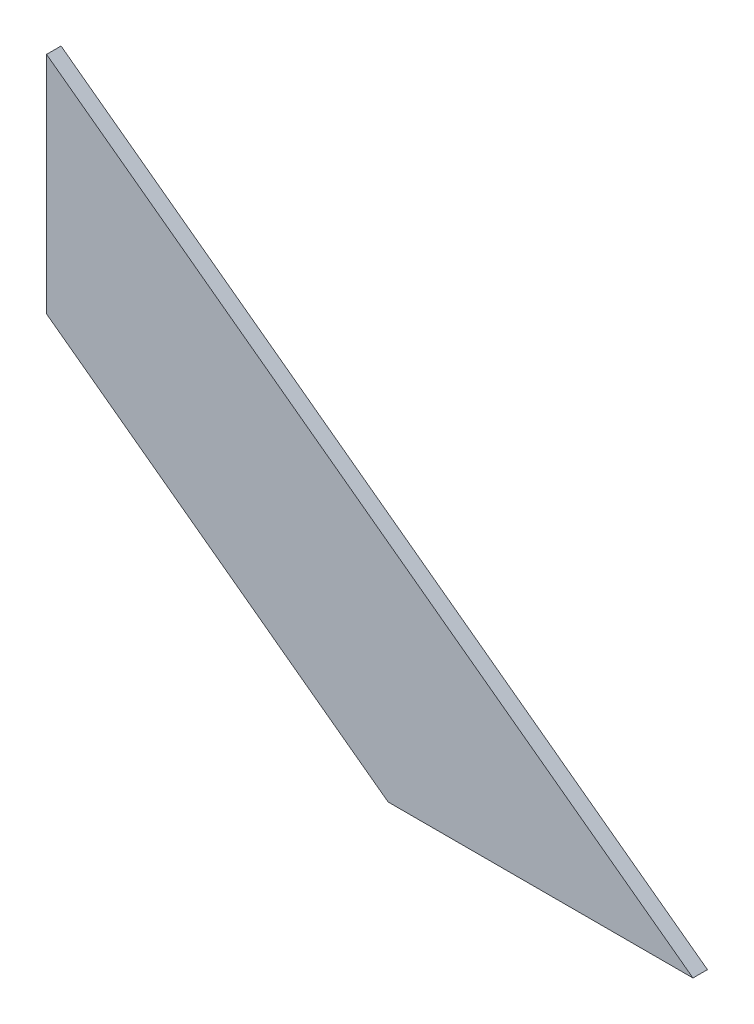
from build123d import *

# Parameters (mm, degrees)
BOSS_EXTRUDE1_DEPTH = 1.524


with BuildPart() as part:
    # Sketch4 → Boss-Extrude1 (new body)
    with BuildSketch(Plane(origin=(0, 0, 0), x_dir=(-1, 0, 0), z_dir=(0, 0, -1))):
        Polygon((471.292522592, -30.261666621), (539.362495023, 19.935354845), (539.362495023, -3.734275458), (503.389866918, -30.261666621), align=None)
    extrude(amount=BOSS_EXTRUDE1_DEPTH)


solid = part.part
